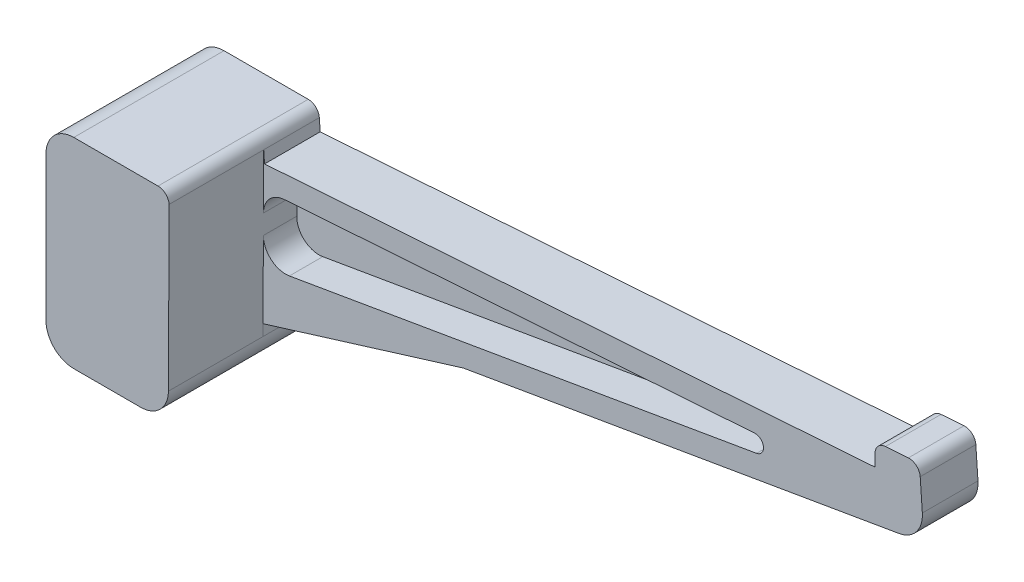
from build123d import *

# Parameters (mm, degrees)
BOSS_EXTRUDE1_DEPTH = 10
BOSS_EXTRUDE2_DEPTH = 10
BOSS_EXTRUDE3_DEPTH = 15
BOSS_EXTRUDE4_DEPTH = 2
CUT_EXTRUDE1_DEPTH  = 6


with BuildPart() as part:
    # Sketch1 → Boss-Extrude1 (new body)
    with BuildSketch(Plane.XY):
        with BuildLine():
            Line((-5, 10), (10.134969828, 10))
            ThreePointArc((10.134969828, 10), (11.498966548, 9.462707403), (12.130097928, 8.139512947))
            Line((12.130097928, 8.139512947), (12.279025895, 6.009743799))
            Line((12.279025895, 6.009743799), (122.011071424, 13.682955911))
            Line((122.011071424, 13.682955911), (122.011071424, 15.827693331))
            ThreePointArc((122.011071424, 15.827693331), (122.54836402, 17.191690051), (123.871558476, 17.822821431))
            Line((123.871558476, 17.822821431), (127.996455725, 18.111262346))
            ThreePointArc((127.996455725, 18.111262346), (129.448086731, 17.625553406), (130.131096773, 16.255647193))
            Line((130.131096773, 16.255647193), (130.513028814, 10.79376454))
            ThreePointArc((130.513028814, 10.79376454), (129.45752894, 7.356802052), (126.3687377, 5.516649939))
            Line((126.3687377, 5.516649939), (12, -14.058605554))
            Line((12, -14.058605554), (12, -21))
            ThreePointArc((12, -21), (10.535533906, -24.535533906), (7, -26))
            Line((7, -26), (-5, -26))
            ThreePointArc((-5, -26), (-8.535533906, -24.535533906), (-10, -21))
            Line((-10, -21), (-10, -14))
            Line((-10, -14), (-3, -14))
            Line((-3, -14), (-3, -18))
            ThreePointArc((-3, -18), (-2.414213562, -19.414213562), (-1, -20))
            Line((-1, -20), (4, -20))
            ThreePointArc((4, -20), (5.414213562, -19.414213562), (6, -18))
            Line((6, -18), (6, 2))
            ThreePointArc((6, 2), (5.414213562, 3.414213562), (4, 4))
            Line((4, 4), (-1, 4))
            ThreePointArc((-1, 4), (-2.414213562, 3.414213562), (-3, 2))
            Line((-3, 2), (-3, -2))
            Line((-3, -2), (-10, -2))
            Line((-10, -2), (-10, 5))
            ThreePointArc((-10, 5), (-8.535533906, 8.535533906), (-5, 10))
        make_face()
    extrude(amount=BOSS_EXTRUDE1_DEPTH)

    # Sketch4 → Boss-Extrude2 (add)
    with BuildSketch(Plane.XY.offset(10)):
        Polygon((12, -18.990256201), (48, -7.896876292), (12, -14.058605554), align=None)
    extrude(amount=-BOSS_EXTRUDE2_DEPTH)

    # Sketch5 → Boss-Extrude3 (add)
    with BuildSketch(Plane.XY.offset(10)):
        with BuildLine():
            Line((12, -21), (12.130097928, 8.139512947))
            ThreePointArc((12.130097928, 8.139512947), (11.498966548, 9.462707403), (10.134969828, 10))
            Line((10.134969828, 10), (-5, 10))
            ThreePointArc((-5, 10), (-8.535533906, 8.535533906), (-10, 5))
            Line((-10, 5), (-10, -2))
            Line((-10, -2), (-3, -2))
            Line((-3, -2), (-3, 2))
            ThreePointArc((-3, 2), (-2.414213562, 3.414213562), (-1, 4))
            Line((-1, 4), (4, 4))
            ThreePointArc((4, 4), (5.414213562, 3.414213562), (6, 2))
            Line((6, 2), (6, -18))
            ThreePointArc((6, -18), (5.414213562, -19.414213562), (4, -20))
            Line((4, -20), (-1, -20))
            ThreePointArc((-1, -20), (-2.414213562, -19.414213562), (-3, -18))
            Line((-3, -18), (-3, -14))
            Line((-3, -14), (-10, -14))
            Line((-10, -14), (-10, -21))
            ThreePointArc((-10, -21), (-8.535533906, -24.535533906), (-5, -26))
            Line((-5, -26), (7, -26))
            ThreePointArc((7, -26), (10.535533906, -24.535533906), (12, -21))
        make_face()
    extrude(amount=BOSS_EXTRUDE3_DEPTH)

    # Sketch6 → Boss-Extrude4 (add)
    with BuildSketch(Plane.XY.offset(25)):
        with BuildLine():
            Line((-10, 5), (-10, -21))
            ThreePointArc((-10, -21), (-8.535533906, -24.535533906), (-5, -26))
            Line((-5, -26), (7, -26))
            ThreePointArc((7, -26), (10.535533906, -24.535533906), (12, -21))
            Line((12, -21), (12.130097928, 8.139512947))
            ThreePointArc((12.130097928, 8.139512947), (11.498966548, 9.462707403), (10.134969828, 10))
            Line((10.134969828, 10), (-5, 10))
            ThreePointArc((-5, 10), (-8.535533906, 8.535533906), (-10, 5))
        make_face()
    extrude(amount=BOSS_EXTRUDE4_DEPTH)

    # Sketch2 → Cut-Extrude1 (cut)
    with BuildSketch(Plane.XY.offset(10)):
        with BuildLine():
            Line((12.07041778, -5.227728761), (12.086053037, -1.725722453))
            ThreePointArc((12.086053037, -1.725722453), (13.166695385, 0.990936179), (15.806987276, 2.246675299))
            Line((15.806987276, 2.246675299), (100.359457674, 8.159159996))
            ThreePointArc((100.359457674, 8.159159996), (101.953365437, 6.84188311), (100.717151126, 5.18431425))
            Line((100.717151126, 5.18431425), (16.745201224, -9.188252997))
            ThreePointArc((16.745201224, -9.188252997), (13.484730649, -8.29754203), (12.07041778, -5.227728761))
        make_face()
    extrude(amount=-CUT_EXTRUDE1_DEPTH, mode=Mode.SUBTRACT)


solid = part.part
